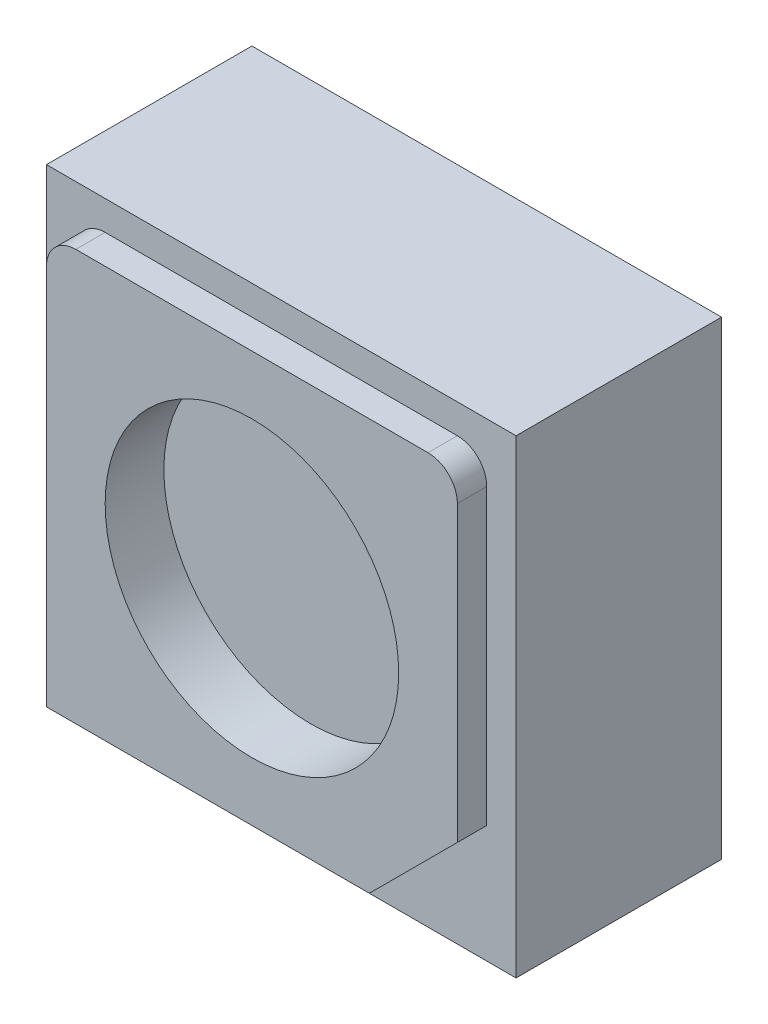
from build123d import *

# Parameters (mm, degrees)
SKETCH1_W           = 80
SKETCH1_H           = 80
BOSS_EXTRUDE1_DEPTH = 35
BOSS_EXTRUDE2_START = 35
BOSS_EXTRUDE2_DEPTH = 5
CUT_EXTRUDE1_START  = 40
SKETCH3_R           = 25
CUT_EXTRUDE1_DEPTH  = 10


with BuildPart() as part:
    # Sketch1 → Boss-Extrude1 (new body)
    with BuildSketch(Plane.XY):
        with Locations((40, 40)):
            Rectangle(SKETCH1_W, SKETCH1_H)
    extrude(amount=BOSS_EXTRUDE1_DEPTH)

    # Sketch2 → Boss-Extrude2 (add)
    with BuildSketch(Plane.XY.offset(BOSS_EXTRUDE2_START)):
        with BuildLine():
            Line((60, 5), (75, 20))
            Line((75, 20), (75, 70))
            ThreePointArc((75, 70), (73.535533906, 73.535533906), (70, 75))
            Line((70, 75), (10, 75))
            ThreePointArc((10, 75), (6.464466094, 73.535533906), (5, 70))
            Line((5, 70), (5, 5))
            Line((5, 5), (60, 5))
        make_face()
    extrude(amount=BOSS_EXTRUDE2_DEPTH)

    # Sketch3 → Cut-Extrude1 (cut)
    with BuildSketch(Plane.XY.offset(CUT_EXTRUDE1_START)):
        with Locations((40, 40)):
            Circle(SKETCH3_R)
    extrude(amount=-CUT_EXTRUDE1_DEPTH, mode=Mode.SUBTRACT)


solid = part.part
